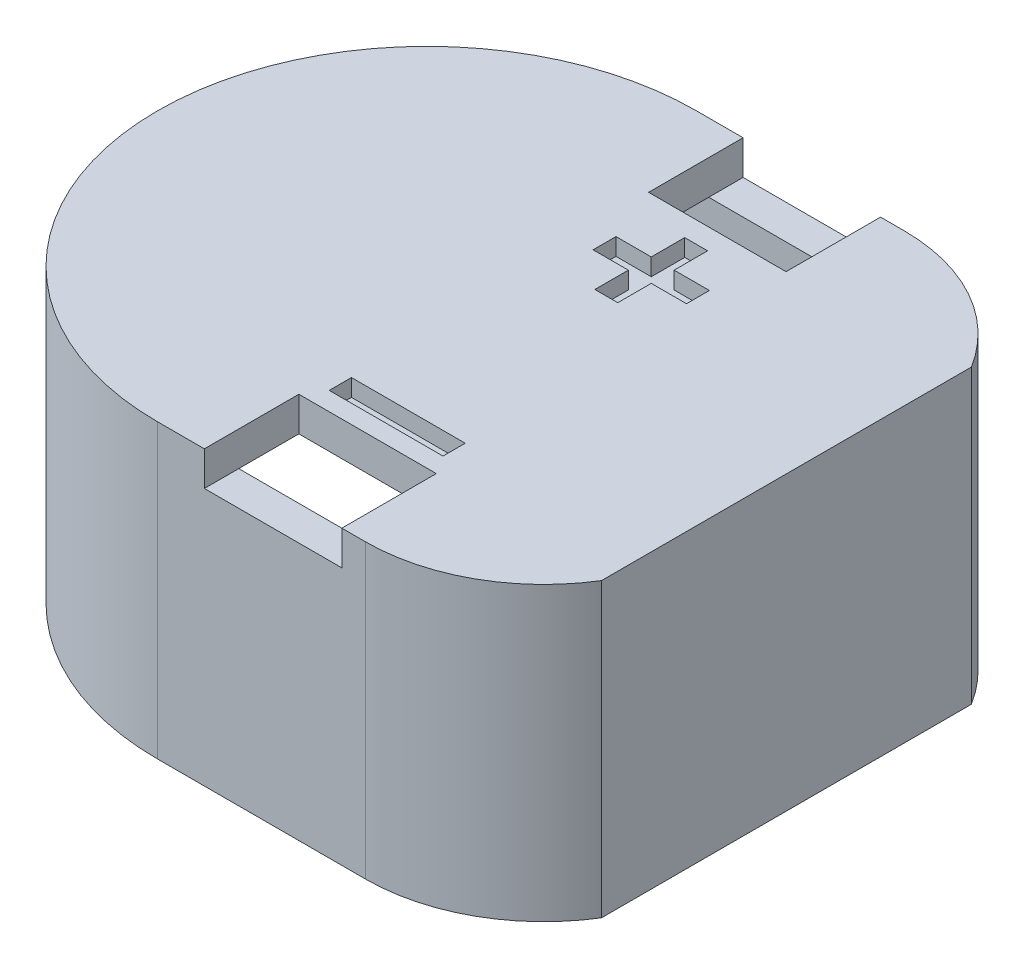
from build123d import *

# Parameters (mm, degrees)
BOSS_EXTRUDE1_DEPTH = 15
BOSS_EXTRUDE2_DEPTH = 2
SKETCH4_W           = 6.62021856
SKETCH4_H           = 1.294383367
CUT_EXTRUDE1_DEPTH  = 1


with BuildPart() as part:
    # Sketch1 → Boss-Extrude1 (new body)
    with BuildSketch(Plane(origin=(0, 0, 0), x_dir=(1, 0, 0), z_dir=(0, 1, 0))):
        with BuildLine():
            Line((95.929523932, 46.874695494), (108.027641063, 46.874695494))
            ThreePointArc((108.027641063, 46.874695494), (113.077675482, 48.185488052), (116.852687564, 51.786919511))
            Line((116.852687564, 51.786919511), (116.852687564, 73.318230601))
            ThreePointArc((116.852687564, 73.318230601), (113.077675482, 76.919662059), (108.027641063, 78.230454618))
            Line((108.027641063, 78.230454618), (95.929523932, 78.230454618))
            ThreePointArc((95.929523932, 78.230454618), (80.25164437, 62.552575056), (95.929523932, 46.874695494))
        make_face()
        with BuildLine():
            Line((95.929523932, 76.230454618), (108.027641063, 76.230454618))
            ThreePointArc((108.027641063, 76.230454618), (111.866170296, 75.300049315), (114.852687564, 72.715349081))
            Line((114.852687564, 72.715349081), (114.852687564, 52.389801031))
            ThreePointArc((114.852687564, 52.389801031), (111.866170296, 49.805100796), (108.027641063, 48.874695494))
            Line((108.027641063, 48.874695494), (95.929523932, 48.874695494))
            ThreePointArc((95.929523932, 48.874695494), (82.25164437, 62.552575056), (95.929523932, 76.230454618))
        make_face(mode=Mode.SUBTRACT)
    extrude(amount=BOSS_EXTRUDE1_DEPTH)

    # Sketch3 → Boss-Extrude2 (add)
    with BuildSketch(Plane(origin=(0, 15, 0), x_dir=(1, 0, 0), z_dir=(0, 1, 0))):
        with BuildLine():
            Line((108.027641063, 76.230454618), (106.652687564, 76.230454618))
            Line((106.652687564, 76.230454618), (106.652687564, 72.730454618))
            Line((106.652687564, 72.730454618), (98.652687564, 72.730454618))
            Line((98.652687564, 72.730454618), (98.652687564, 76.230454618))
            Line((98.652687564, 76.230454618), (95.929523932, 76.230454618))
            ThreePointArc((95.929523932, 76.230454618), (82.25164437, 62.552575056), (95.929523932, 48.874695494))
            Line((95.929523932, 48.874695494), (98.652687564, 48.874695494))
            Line((98.652687564, 48.874695494), (98.652687564, 52.374695494))
            Line((98.652687564, 52.374695494), (106.652687564, 52.374695494))
            Line((106.652687564, 52.374695494), (106.652687564, 48.874695494))
            Line((106.652687564, 48.874695494), (108.027641063, 48.874695494))
            ThreePointArc((108.027641063, 48.874695494), (111.866170296, 49.805100796), (114.852687564, 52.389801031))
            Line((114.852687564, 52.389801031), (114.852687564, 72.715349081))
            ThreePointArc((114.852687564, 72.715349081), (111.866170296, 75.300049315), (108.027641063, 76.230454618))
        make_face()
        with BuildLine():
            Line((98.652687564, 76.230454618), (98.652687564, 78.230454618))
            Line((98.652687564, 78.230454618), (95.929523932, 78.230454618))
            ThreePointArc((95.929523932, 78.230454618), (80.25164437, 62.552575056), (95.929523932, 46.874695494))
            Line((95.929523932, 46.874695494), (98.652687564, 46.874695494))
            Line((98.652687564, 46.874695494), (98.652687564, 48.874695494))
            Line((98.652687564, 48.874695494), (95.929523932, 48.874695494))
            ThreePointArc((95.929523932, 48.874695494), (82.25164437, 62.552575056), (95.929523932, 76.230454618))
            Line((95.929523932, 76.230454618), (98.652687564, 76.230454618))
        make_face()
        with BuildLine():
            Line((108.027641063, 78.230454618), (106.652687564, 78.230454618))
            Line((106.652687564, 78.230454618), (106.652687564, 76.230454618))
            Line((106.652687564, 76.230454618), (108.027641063, 76.230454618))
            ThreePointArc((108.027641063, 76.230454618), (111.866170296, 75.300049315), (114.852687564, 72.715349081))
            Line((114.852687564, 72.715349081), (114.852687564, 52.389801031))
            ThreePointArc((114.852687564, 52.389801031), (111.866170296, 49.805100796), (108.027641063, 48.874695494))
            Line((108.027641063, 48.874695494), (106.652687564, 48.874695494))
            Line((106.652687564, 48.874695494), (106.652687564, 46.874695494))
            Line((106.652687564, 46.874695494), (108.027641063, 46.874695494))
            ThreePointArc((108.027641063, 46.874695494), (113.077675482, 48.185488052), (116.852687564, 51.786919511))
            Line((116.852687564, 51.786919511), (116.852687564, 73.318230601))
            ThreePointArc((116.852687564, 73.318230601), (113.077675482, 76.919662059), (108.027641063, 78.230454618))
        make_face()
    extrude(amount=BOSS_EXTRUDE2_DEPTH)

    # Sketch4 → Cut-Extrude1 (cut)
    with BuildSketch(Plane(origin=(0, 17, 0), x_dir=(1, 0, 0), z_dir=(0, 1, 0))):
        with Locations((102.652687564, 54.099354042)):
            Rectangle(SKETCH4_W, SKETCH4_H)
        Polygon((103.319354231, 68.217634105), (103.319354231, 66.268916157), (101.986020897, 66.268916157), (101.986020897, 68.217634105), (99.934738846, 68.217634105), (99.934738846, 69.550967439), (101.986020897, 69.550967439), (101.986020897, 71.499685387), (103.319354231, 71.499685387), (103.319354231, 69.550967439), (105.370636282, 69.550967439), (105.370636282, 68.217634105), align=None)
    extrude(amount=-CUT_EXTRUDE1_DEPTH, mode=Mode.SUBTRACT)


solid = part.part
